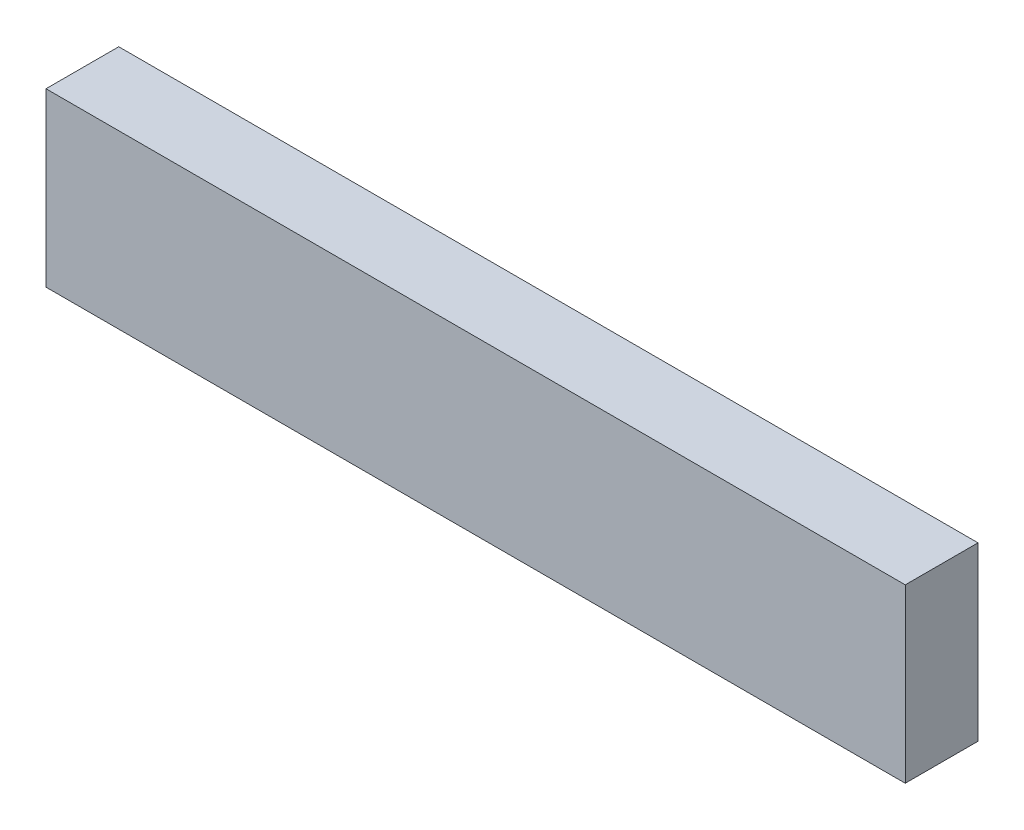
from build123d import *

# Parameters (mm, degrees)
SKETCH1_W           = 75
SKETCH1_H           = 15
BOSS_EXTRUDE1_DEPTH = 6.35


with BuildPart() as part:
    # Sketch1 → Boss-Extrude1 (new body)
    with BuildSketch(Plane.XY):
        with Locations((37.5, 7.5)):
            Rectangle(SKETCH1_W, SKETCH1_H)
    extrude(amount=BOSS_EXTRUDE1_DEPTH)


solid = part.part
